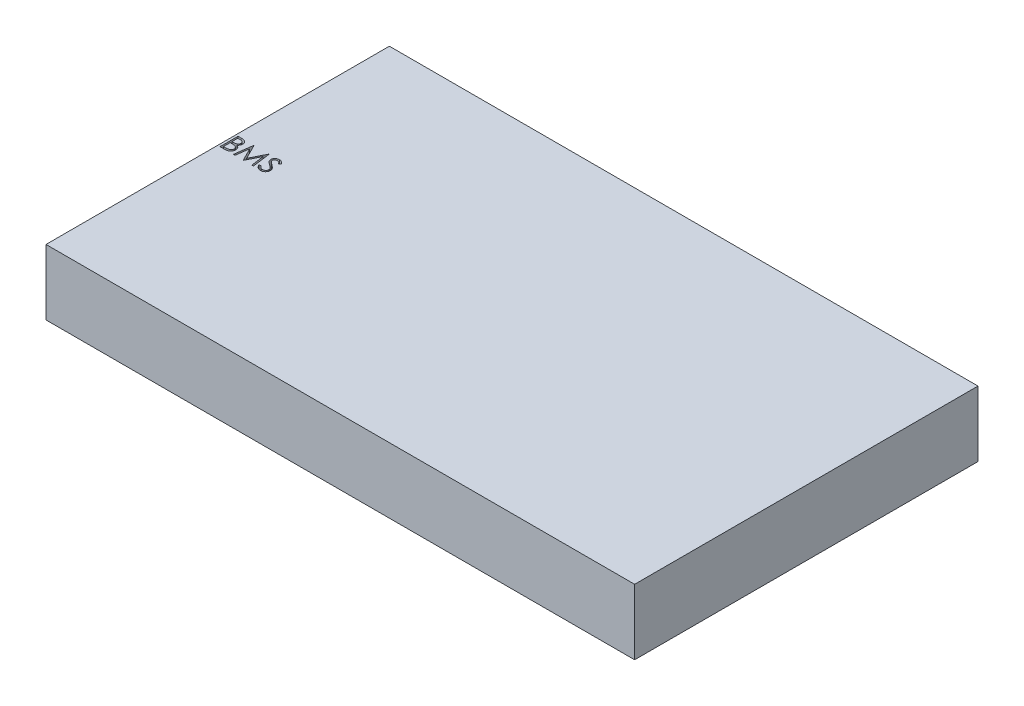
from build123d import *

# Parameters (mm, degrees)
SKETCH1_W           = 114.3
SKETCH1_H           = 66.675
BOSS_EXTRUDE1_DEPTH = 12.7
CUT_EXTRUDE1_DEPTH  = 13.7


with BuildPart() as part:
    # Sketch1 → Boss-Extrude1 (new body)
    with BuildSketch(Plane(origin=(0, 0, 0), x_dir=(1, 0, 0), z_dir=(0, 1, 0))):
        with Locations((57.15, 33.3375)):
            Rectangle(SKETCH1_W, SKETCH1_H)
    extrude(amount=BOSS_EXTRUDE1_DEPTH)

    # Sketch2 → Cut-Extrude1 (cut, through all)
    with BuildSketch(Plane(origin=(0, 12.7, 0), x_dir=(1, 0, 0), z_dir=(0, 1, 0))):
        with BuildLine():
            Line((0.448717949, 36.8375), (1.131610577, 36.8375))
            add(Edge.make_bspline(
                [(1.131610577, 36.8375), (1.165039055, 36.83732425), (1.229831765, 36.836983602), (1.324051207, 36.83170047), (1.412300018, 36.824496801), (1.49460379, 36.813066708), (1.570924493, 36.799274931), (1.64149213, 36.782573115), (1.706082302, 36.762546501), (1.783195039, 36.73070022), (1.871115699, 36.683377051), (1.966314092, 36.613448486), (2.047718332, 36.527916023), (2.117904649, 36.431433368), (2.173705768, 36.325297596), (2.214075066, 36.212038407), (2.239632941, 36.093116665), (2.242261375, 36.011473487), (2.243589744, 35.97021234)],
                knots=[0, 0, 0, 0, 0.00010027, 0.000194349, 0.000283026, 0.000365821, 0.000443519, 0.000515622, 0.000583254, 0.00064614, 0.000765662, 0.000881909, 0.000998927, 0.001118415, 0.001238844, 0.00135727, 0.001478274, 0.001601912, 0.001601912, 0.001601912, 0.001601912], degree=3))
            add(Edge.make_bspline(
                [(2.243589744, 35.97021234), (2.242496525, 35.931559784), (2.240348248, 35.855603867), (2.219805488, 35.744509758), (2.18764482, 35.638758539), (2.142939571, 35.538736154), (2.084837575, 35.44670254), (2.015979256, 35.361915274), (1.932902454, 35.287964217), (1.870659214, 35.246621315), (1.839042468, 35.225620994)],
                knots=[0, 0, 0, 0, 0.000115857, 0.00022767, 0.000337672, 0.000446877, 0.000555233, 0.000663318, 0.000773539, 0.000887324, 0.000887324, 0.000887324, 0.000887324], degree=3))
            add(Edge.make_bspline(
                [(1.839042468, 35.225620994), (1.878802896, 35.210355995), (1.954874443, 35.18115027), (2.059560455, 35.129514806), (2.1497553, 35.073352696), (2.226152446, 35.012020846), (2.291490101, 34.945912035), (2.348543043, 34.874056921), (2.397224417, 34.795518163), (2.438937341, 34.711114627), (2.471486097, 34.621708159), (2.495862001, 34.528137383), (2.50982945, 34.430737828), (2.511817091, 34.364452448), (2.512820513, 34.330989583)],
                knots=[0, 0, 0, 0, 0.000127722, 0.000244363, 0.000349599, 0.000445847, 0.000537565, 0.000627901, 0.000720503, 0.000814257, 0.000909859, 0.001005428, 0.001103887, 0.001204268, 0.001204268, 0.001204268, 0.001204268], degree=3))
            add(Edge.make_bspline(
                [(2.512820513, 34.330989583), (2.511843667, 34.296822711), (2.509921695, 34.229598433), (2.495741723, 34.130843299), (2.471732616, 34.036468352), (2.43866147, 33.945863169), (2.395499155, 33.859203035), (2.342971191, 33.776389771), (2.280339627, 33.69825544), (2.210276758, 33.623931817), (2.131014613, 33.55710403), (2.045498858, 33.497588323), (1.952652538, 33.448642261), (1.854000544, 33.407526239), (1.748436228, 33.376119041), (1.63643362, 33.354146467), (1.518089319, 33.33934143), (1.436879567, 33.338124225), (1.395232372, 33.3375)],
                knots=[0, 0, 0, 0, 0.000102481, 0.000201635, 0.000298562, 0.000394165, 0.000490425, 0.000588455, 0.000687769, 0.000790423, 0.000894381, 0.000998232, 0.001102369, 0.001208616, 0.001318415, 0.001432129, 0.001550749, 0.00167562, 0.00167562, 0.00167562, 0.00167562], degree=3))
            Line((1.395232372, 33.3375), (0.448717949, 33.3375))
            Line((0.448717949, 33.3375), (0.448717949, 36.8375))
        make_face()
        with BuildLine():
            Line((0.762820513, 36.478525641), (0.762820513, 35.356730769))
            Line((0.762820513, 35.356730769), (0.973858173, 35.356730769))
            add(Edge.make_bspline(
                [(0.973858173, 35.356730769), (1.004706968, 35.357130692), (1.064313128, 35.357903425), (1.150633024, 35.360116942), (1.230758042, 35.366314985), (1.304549876, 35.372511248), (1.371892319, 35.382585835), (1.432636181, 35.394577958), (1.487734778, 35.407260863), (1.551274323, 35.42883035), (1.623347272, 35.460708025), (1.700180376, 35.510179861), (1.767914846, 35.569104215), (1.825112033, 35.637095176), (1.871923504, 35.711961362), (1.904437219, 35.792508243), (1.926484503, 35.876728375), (1.928476035, 35.934546627), (1.929487179, 35.963902244)],
                knots=[0, 0, 0, 0, 9.2559e-05, 0.000178842, 0.000258967, 0.000333616, 0.000400942, 0.000463093, 0.000519379, 0.000570374, 0.000664201, 0.000755025, 0.000843472, 0.000932526, 0.001020669, 0.001107124, 0.001192318, 0.001280185, 0.001280185, 0.001280185, 0.001280185], degree=3))
            add(Edge.make_bspline(
                [(1.929487179, 35.963902244), (1.928960999, 35.983328015), (1.927928839, 36.021433787), (1.919475537, 36.076983141), (1.905107962, 36.129226894), (1.886653669, 36.178881004), (1.86086498, 36.224392854), (1.830501517, 36.26733605), (1.793815827, 36.306248169), (1.752058514, 36.342617667), (1.704049891, 36.374862195), (1.649818599, 36.403102958), (1.588630922, 36.425843735), (1.521518067, 36.445759887), (1.44744698, 36.459748181), (1.367272427, 36.471401569), (1.280337708, 36.477334311), (1.220192605, 36.478119673), (1.189102564, 36.478525641)],
                knots=[0, 0, 0, 0, 5.8261e-05, 0.000114285, 0.000168029, 0.000220632, 0.000272728, 0.000324483, 0.000378062, 0.000432741, 0.000490301, 0.000551137, 0.000615721, 0.000685833, 0.000760908, 0.00084162, 0.000928788, 0.00102206, 0.00102206, 0.00102206, 0.00102206], degree=3))
            Line((1.189102564, 36.478525641), (0.762820513, 36.478525641))
        make_face(mode=Mode.SUBTRACT)
        with BuildLine():
            Line((0.762820513, 34.99775641), (0.762820513, 33.696474359))
            Line((0.762820513, 33.696474359), (1.210136218, 33.696474359))
            add(Edge.make_bspline(
                [(1.210136218, 33.696474359), (1.242155144, 33.696858106), (1.303867402, 33.697597729), (1.392968633, 33.700012283), (1.475551736, 33.705504559), (1.551239872, 33.714150409), (1.620850325, 33.723528858), (1.683548028, 33.736140139), (1.739841221, 33.750589099), (1.805115529, 33.772923272), (1.878619037, 33.807619743), (1.957829894, 33.859933969), (2.028256112, 33.922257277), (2.088061371, 33.994388191), (2.13707436, 34.072819518), (2.172729815, 34.155964868), (2.194720671, 34.242450395), (2.197382841, 34.301417108), (2.198717949, 34.330989583)],
                knots=[0, 0, 0, 0, 9.6064e-05, 0.000185151, 0.000267373, 0.000344257, 0.000413665, 0.000478015, 0.000536005, 0.000587888, 0.000684801, 0.000778918, 0.000871787, 0.000965866, 0.001059062, 0.00114827, 0.001236355, 0.001324974, 0.001324974, 0.001324974, 0.001324974], degree=3))
            add(Edge.make_bspline(
                [(2.198717949, 34.330989583), (2.198441844, 34.349482924), (2.197894089, 34.386171306), (2.189633474, 34.440087125), (2.177619605, 34.492312998), (2.162088171, 34.542990739), (2.139468704, 34.591204115), (2.113062159, 34.637906674), (2.082100757, 34.683160154), (2.033856591, 34.740372407), (1.963684607, 34.80628942), (1.863977831, 34.870826923), (1.750605533, 34.92287473), (1.66837804, 34.944974206), (1.625901442, 34.956390224)],
                knots=[0, 0, 0, 0, 5.5429e-05, 0.000109963, 0.000163198, 0.000216191, 0.000268588, 0.000322593, 0.000377046, 0.000432793, 0.000546889, 0.000664343, 0.000787646, 0.000919405, 0.000919405, 0.000919405, 0.000919405], degree=3))
            add(Edge.make_bspline(
                [(1.625901442, 34.956390224), (1.608872346, 34.959845308), (1.571949754, 34.967336643), (1.511742174, 34.975244346), (1.443006305, 34.982289406), (1.365583428, 34.987500564), (1.279375586, 34.992887107), (1.184198668, 34.994981929), (1.080441353, 34.997481189), (1.008448981, 34.997662323), (0.971053686, 34.99775641)],
                knots=[0, 0, 0, 0, 5.2115e-05, 0.000112995, 0.000182062, 0.000259389, 0.000345767, 0.00044116, 0.000544948, 0.000657129, 0.000657129, 0.000657129, 0.000657129], degree=3))
            Line((0.971053686, 34.99775641), (0.762820513, 34.99775641))
        make_face(mode=Mode.SUBTRACT)
        Polygon((3.051282051, 33.3375), (3.513321314, 36.8375), (3.558193109, 36.8375), (5.003205128, 33.965705128), (6.444010417, 36.8375), (6.488882212, 36.8375), (6.955128205, 33.3375), (6.641025641, 33.3375), (6.304487179, 35.853826122), (5.041766827, 33.3375), (4.970252404, 33.3375), (3.701923077, 35.861538462), (3.367487981, 33.3375), align=None)
        with BuildLine():
            Line((7.314102564, 34.012680288), (7.609975962, 34.190064103))
            add(Edge.make_bspline(
                [(7.609975962, 34.190064103), (7.637494199, 34.143999718), (7.690218079, 34.055742134), (7.778169439, 33.936484093), (7.86930235, 33.835121937), (7.964291683, 33.752245329), (8.062557631, 33.686996442), (8.164741685, 33.640794211), (8.270499496, 33.611978235), (8.342473317, 33.608478149), (8.378405449, 33.606730769)],
                knots=[0, 0, 0, 0, 0.000160901, 0.00030828, 0.000443778, 0.00056903, 0.000685513, 0.000796284, 0.00090427, 0.001011928, 0.001011928, 0.001011928, 0.001011928], degree=3))
            add(Edge.make_bspline(
                [(8.378405449, 33.606730769), (8.409092309, 33.607585442), (8.469929082, 33.609279832), (8.559491325, 33.625560634), (8.646473128, 33.650572763), (8.729081765, 33.686393694), (8.80617738, 33.72973218), (8.873784075, 33.782078358), (8.932230188, 33.840684563), (8.980039303, 33.906067218), (9.016719338, 33.976384367), (9.044911407, 34.048560318), (9.06055648, 34.123728886), (9.062913234, 34.174339349), (9.064102564, 34.199879808)],
                knots=[0, 0, 0, 0, 9.1978e-05, 0.000182347, 0.000272202, 0.000362975, 0.000451852, 0.000536835, 0.000618639, 0.000699414, 0.000778765, 0.000855983, 0.0009312, 0.001007828, 0.001007828, 0.001007828, 0.001007828], degree=3))
            add(Edge.make_bspline(
                [(9.064102564, 34.199879808), (9.062628253, 34.229020657), (9.059631195, 34.288259747), (9.034299715, 34.3756594), (8.994450468, 34.46215197), (8.957687825, 34.515653235), (8.938601763, 34.543429487)],
                knots=[0, 0, 0, 0, 8.7281e-05, 0.000177429, 0.000270909, 0.000371844, 0.000371844, 0.000371844, 0.000371844], degree=3))
            add(Edge.make_bspline(
                [(8.938601763, 34.543429487), (8.922931149, 34.563476311), (8.890032654, 34.605562109), (8.833475142, 34.668207345), (8.767109027, 34.732825764), (8.693205473, 34.801884821), (8.609072384, 34.872172617), (8.517344869, 34.947040895), (8.41568101, 35.023642472), (8.344381514, 35.075015038), (8.307592147, 35.101522436)],
                knots=[0, 0, 0, 0, 7.6319e-05, 0.000160223, 0.000252933, 0.000354147, 0.000463581, 0.000581729, 0.000709336, 0.000845369, 0.000845369, 0.000845369, 0.000845369], degree=3))
            add(Edge.make_bspline(
                [(8.307592147, 35.101522436), (8.270768151, 35.127751024), (8.200363475, 35.177898086), (8.101904892, 35.25232237), (8.013860429, 35.320366239), (7.936621413, 35.382670251), (7.870221816, 35.439242856), (7.814138405, 35.489540795), (7.769799848, 35.534924356), (7.745144267, 35.564365698), (7.734074519, 35.577584135)],
                knots=[0, 0, 0, 0, 0.000135623, 0.000259301, 0.000370234, 0.000469439, 0.00055697, 0.000631911, 0.000695377, 0.00074709, 0.00074709, 0.00074709, 0.00074709], degree=3))
            add(Edge.make_bspline(
                [(7.734074519, 35.577584135), (7.718601974, 35.598185171), (7.688173137, 35.638699875), (7.648007132, 35.702024733), (7.613867969, 35.766847998), (7.587105637, 35.833343863), (7.564569418, 35.900578792), (7.549411487, 35.969430038), (7.53992009, 36.039588656), (7.538948104, 36.086802157), (7.538461538, 36.110436699)],
                knots=[0, 0, 0, 0, 7.727e-05, 0.000151962, 0.000224716, 0.000296717, 0.00036678, 0.0004372, 0.000507902, 0.000578771, 0.000578771, 0.000578771, 0.000578771], degree=3))
            add(Edge.make_bspline(
                [(7.538461538, 36.110436699), (7.539766747, 36.147466473), (7.542349268, 36.220734537), (7.564189785, 36.327765367), (7.598662678, 36.429951785), (7.646957566, 36.526282118), (7.709214919, 36.614248099), (7.781260894, 36.694861586), (7.86707238, 36.762630168), (7.961225003, 36.821842227), (8.064281375, 36.868188152), (8.172272279, 36.903149132), (8.285369351, 36.92295839), (8.361972485, 36.925801155), (8.400841346, 36.92724359)],
                knots=[0, 0, 0, 0, 0.000110999, 0.000219625, 0.000326272, 0.00043382, 0.000541574, 0.000648775, 0.000756959, 0.000868438, 0.000981703, 0.00109501, 0.001208203, 0.0013248, 0.0013248, 0.0013248, 0.0013248], degree=3))
            add(Edge.make_bspline(
                [(8.400841346, 36.92724359), (8.442085446, 36.925821038), (8.524106798, 36.922992037), (8.644756014, 36.898394506), (8.76091673, 36.857693834), (8.854359995, 36.811505176), (8.927492756, 36.76537376), (8.983265489, 36.723353936), (9.03978294, 36.674978827), (9.097500995, 36.620119581), (9.155441654, 36.55827283), (9.214465106, 36.489862141), (9.274709375, 36.415305585), (9.313465235, 36.362081085), (9.333333333, 36.334795673)],
                knots=[0, 0, 0, 0, 0.000123638, 0.000245877, 0.000367608, 0.000492088, 0.000557638, 0.000626769, 0.000701372, 0.00078072, 0.000865532, 0.000955497, 0.001051745, 0.001152989, 0.001152989, 0.001152989, 0.001152989], degree=3))
            Line((9.333333333, 36.334795673), (9.049379006, 36.119551282))
            add(Edge.make_bspline(
                [(9.049379006, 36.119551282), (9.032233074, 36.141639972), (8.999214017, 36.184177626), (8.94908453, 36.243748941), (8.901835882, 36.298165421), (8.855285482, 36.345430549), (8.811891851, 36.388132682), (8.769774809, 36.424692439), (8.729540457, 36.455468034), (8.678823547, 36.488311594), (8.615105828, 36.520868098), (8.535121292, 36.548417176), (8.451535017, 36.564972238), (8.394605386, 36.567161126), (8.365785256, 36.568269231)],
                knots=[0, 0, 0, 0, 8.3877e-05, 0.000161528, 0.000233552, 0.000299993, 0.000360485, 0.000416152, 0.000467195, 0.000512312, 0.000597287, 0.000681099, 0.000765389, 0.000851809, 0.000851809, 0.000851809, 0.000851809], degree=3))
            add(Edge.make_bspline(
                [(8.365785256, 36.568269231), (8.329628734, 36.567057531), (8.259904287, 36.564720882), (8.16091405, 36.539200896), (8.071820125, 36.499019036), (7.99526756, 36.442704058), (7.931530583, 36.375983065), (7.885425125, 36.29920421), (7.85767496, 36.214421808), (7.85428868, 36.155280151), (7.852564103, 36.125160256)],
                knots=[0, 0, 0, 0, 0.000108248, 0.000208746, 0.00030443, 0.000399793, 0.000492054, 0.00057947, 0.000666386, 0.000756591, 0.000756591, 0.000756591, 0.000756591], degree=3))
            add(Edge.make_bspline(
                [(7.852564103, 36.125160256), (7.852957229, 36.106408778), (7.853744125, 36.068875158), (7.864718923, 36.013423736), (7.878818252, 35.958112397), (7.901160884, 35.903189814), (7.932006187, 35.847695455), (7.972511363, 35.790673718), (8.023524675, 35.731622009), (8.062601688, 35.693214635), (8.083233173, 35.672936699)],
                knots=[0, 0, 0, 0, 5.616e-05, 0.000112411, 0.000169046, 0.000227244, 0.000289691, 0.000359134, 0.000436702, 0.000523463, 0.000523463, 0.000523463, 0.000523463], degree=3))
            add(Edge.make_bspline(
                [(8.083233173, 35.672936699), (8.090894545, 35.666099673), (8.109096213, 35.649856465), (8.142372138, 35.623264184), (8.186314937, 35.590461412), (8.239777138, 35.549874095), (8.303744499, 35.502792633), (8.378224056, 35.449819021), (8.462385588, 35.389233562), (8.522107504, 35.346876021), (8.553685897, 35.324479167)],
                knots=[0, 0, 0, 0, 3.0802e-05, 7.3177e-05, 0.000127725, 0.000195314, 0.000274544, 0.000365991, 0.000469501, 0.000585644, 0.000585644, 0.000585644, 0.000585644], degree=3))
            add(Edge.make_bspline(
                [(8.553685897, 35.324479167), (8.591671811, 35.296837807), (8.665226267, 35.243314145), (8.769883847, 35.162898465), (8.864777655, 35.084250697), (8.950240859, 35.00787309), (9.027117767, 34.934344997), (9.094555488, 34.862781816), (9.153241168, 34.793696244), (9.216420387, 34.705123668), (9.280978206, 34.596342584), (9.336419714, 34.463064345), (9.371378061, 34.329268025), (9.375949576, 34.239341188), (9.378205128, 34.194971955)],
                knots=[0, 0, 0, 0, 0.000140932, 0.000272896, 0.000395881, 0.000510584, 0.000616697, 0.000714904, 0.000805482, 0.000888372, 0.001041088, 0.001183793, 0.001320341, 0.001453327, 0.001453327, 0.001453327, 0.001453327], degree=3))
            add(Edge.make_bspline(
                [(9.378205128, 34.194971955), (9.37754799, 34.16359359), (9.376246475, 34.101446206), (9.361285561, 34.01019113), (9.339365896, 33.92156026), (9.306328662, 33.836649147), (9.266005504, 33.753904385), (9.214839256, 33.675496484), (9.155531571, 33.599690086), (9.087497806, 33.528506594), (9.013051904, 33.463160398), (8.934368209, 33.405031337), (8.851317936, 33.356563014), (8.76435162, 33.317012172), (8.673449283, 33.286078654), (8.578641499, 33.263665785), (8.479771988, 33.249910074), (8.412571506, 33.248482313), (8.378405449, 33.24775641)],
                knots=[0, 0, 0, 0, 9.4044e-05, 0.000186263, 0.000276729, 0.000367488, 0.000459046, 0.000552398, 0.000647774, 0.000747454, 0.000847311, 0.000944634, 0.001040472, 0.001135227, 0.001230788, 0.001328063, 0.00142712, 0.00152957, 0.00152957, 0.00152957, 0.00152957], degree=3))
            add(Edge.make_bspline(
                [(8.378405449, 33.24775641), (8.351970106, 33.248267592), (8.299432346, 33.249283517), (8.221722864, 33.258264798), (8.145583275, 33.270971901), (8.071968993, 33.291145971), (7.999931581, 33.315622948), (7.929784346, 33.345761281), (7.861493293, 33.381878482), (7.79467571, 33.423173507), (7.729501535, 33.471231252), (7.666582067, 33.527204748), (7.603852882, 33.589550253), (7.543165485, 33.659960816), (7.483292341, 33.737298899), (7.425413931, 33.822288083), (7.368332214, 33.914465436), (7.332516746, 33.979330522), (7.314102564, 34.012680288)],
                knots=[0, 0, 0, 0, 7.9276e-05, 0.000157554, 0.000234438, 0.000310629, 0.000386236, 0.000462555, 0.000539392, 0.000617798, 0.000698008, 0.000781971, 0.000870217, 0.00096315, 0.001060616, 0.001163492, 0.001271478, 0.00138575, 0.00138575, 0.00138575, 0.00138575], degree=3))
        make_face()
    extrude(amount=-CUT_EXTRUDE1_DEPTH, mode=Mode.SUBTRACT)


solid = part.part
